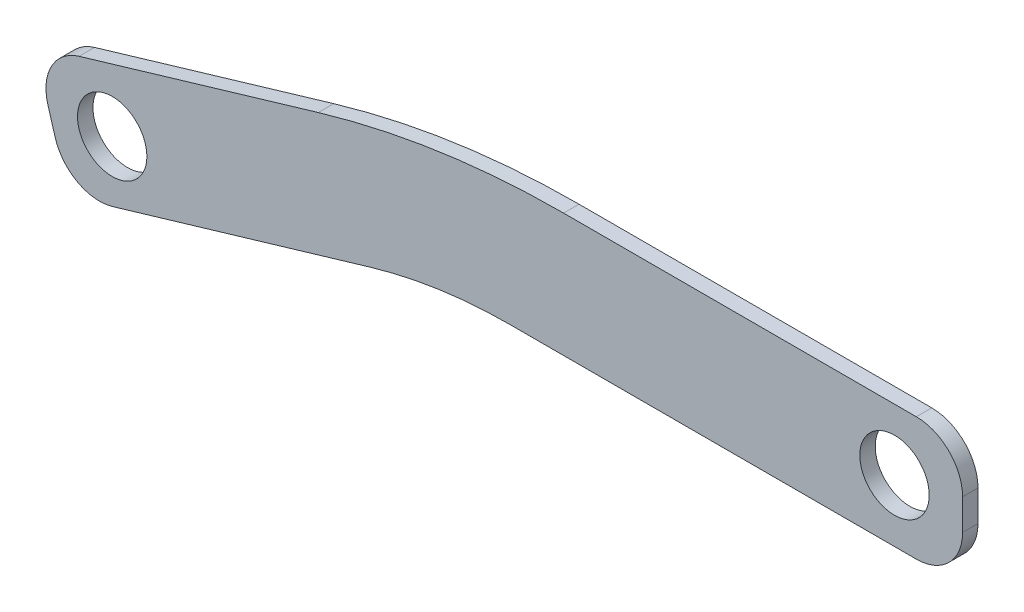
from build123d import *

# Parameters (mm, degrees)
BOSS_EXTRUDE1_DEPTH = 6.35
FILLET1_R           = 203.2
FILLET2_R           = 355.6
FILLET3_R           = 19.05
FILLET4_R           = 19.05
FILLET5_R           = 19.05
FILLET6_R           = 19.05
SKETCH2_R           = 14.2875
CUT_EXTRUDE1_DEPTH  = 6.35


with BuildPart() as part:
    # Sketch1 → Boss-Extrude1 (new body)
    with BuildSketch(Plane.XY):
        Polygon((0, 0), (215.9, 0), (215.9, 50.8), (0, 50.8), (-166.237074401, 1.544570548), (-152.4, -45.155555556), align=None)
    extrude(amount=BOSS_EXTRUDE1_DEPTH)

    # Fillet1
    fillet1_edges = [part.edges().sort_by_distance(p)[0] for p in [
        (0, 0, 3.175),
    ]]
    fillet(fillet1_edges, radius=FILLET1_R)

    # Fillet2
    fillet2_edges = [part.edges().sort_by_distance(p)[0] for p in [
        (0, 50.8, 3.175),
    ]]
    fillet(fillet2_edges, radius=FILLET2_R)

    # Fillet3
    fillet3_edges = [part.edges().sort_by_distance(p)[0] for p in [
        (-166.237074401, 1.544570548, 3.175),
    ]]
    fillet(fillet3_edges, radius=FILLET3_R)

    # Fillet4
    fillet4_edges = [part.edges().sort_by_distance(p)[0] for p in [
        (-152.4, -45.155555556, 3.175),
    ]]
    fillet(fillet4_edges, radius=FILLET4_R)

    # Fillet5
    fillet5_edges = [part.edges().sort_by_distance(p)[0] for p in [
        (215.9, 50.8, 3.175),
    ]]
    fillet(fillet5_edges, radius=FILLET5_R)

    # Fillet6
    fillet6_edges = [part.edges().sort_by_distance(p)[0] for p in [
        (215.9, 0, 3.175),
    ]]
    fillet(fillet6_edges, radius=FILLET6_R)

    # Sketch2 → Cut-Extrude1 (cut)
    with BuildSketch(Plane.XY.offset(6.35)):
        with Locations((-134.33022138, -14.825444286)):
            Circle(SKETCH2_R)
        with Locations((187.858901067, 25.448520628)):
            Circle(SKETCH2_R)
    extrude(amount=-CUT_EXTRUDE1_DEPTH, mode=Mode.SUBTRACT)


solid = part.part
